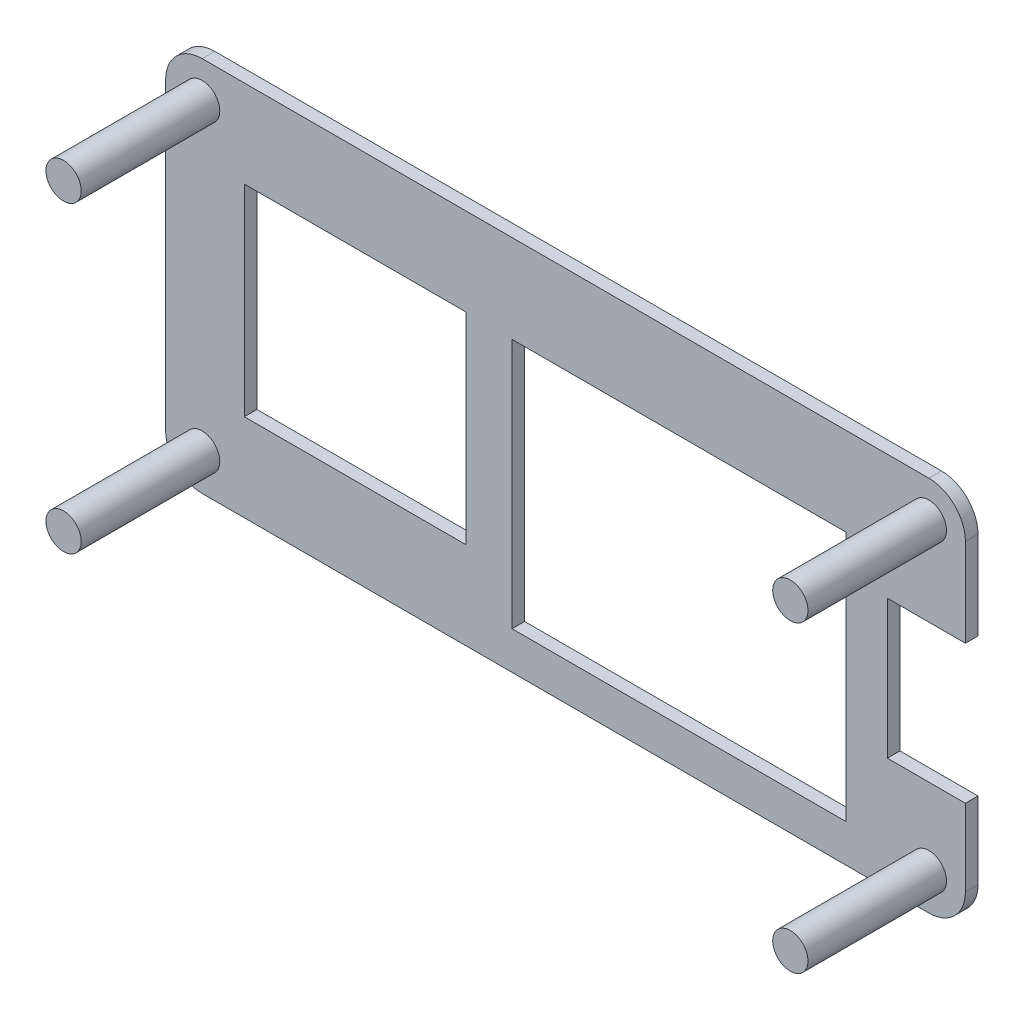
from build123d import *

# Parameters (mm, degrees)
EXTRUDE_1_DEPTH     = 1
SKETCH_2_R          = 1.4
EXTRUDE_2_DEPTH     = 12
SKETCH_10_W         = 17.6
SKETCH_10_H         = 16
SKETCH_10_W_2       = 6.2
SKETCH_10_H_2       = 11
SKETCH_10_W_3       = 26.5
SKETCH_10_H_3       = 19.9
CUT_EXTRUDE_1_DEPTH = 2


with BuildPart() as part:
    # 草图1 → 凸台-拉伸1 (new body)
    with BuildSketch(Plane.XY):
        with BuildLine():
            Line((0, -2.9), (57.7, -2.9))
            ThreePointArc((57.7, -2.9), (59.750609665, -2.050609665), (60.6, 0))
            Line((60.6, 0), (60.6, 24.1))
            ThreePointArc((60.6, 24.1), (59.750609665, 26.150609665), (57.7, 27))
            Line((57.7, 27), (0, 27))
            ThreePointArc((0, 27), (-2.050609665, 26.150609665), (-2.9, 24.1))
            Line((-2.9, 24.1), (-2.9, 0))
            ThreePointArc((-2.9, 0), (-2.050609665, -2.050609665), (0, -2.9))
        make_face()
    extrude(amount=EXTRUDE_1_DEPTH)

    # 草图2 → 凸台-拉伸2 (add)
    with BuildSketch(Plane.XY):
        with Locations((0, 24.1)):
            Circle(SKETCH_2_R)
        Circle(SKETCH_2_R)
        with Locations((57.7, 0)):
            Circle(SKETCH_2_R)
        with Locations((57.7, 24.1)):
            Circle(SKETCH_2_R)
    extrude(amount=EXTRUDE_2_DEPTH)

    # 草图10 → 切除-拉伸1 (cut, through all)
    with BuildSketch(Plane.XY.offset(1)):
        with Locations((12.15, 12.05)):
            Rectangle(SKETCH_10_W, SKETCH_10_H)
        with Locations((57.5, 11.6)):
            Rectangle(SKETCH_10_W_2, SKETCH_10_H_2)
        with Locations((37.85, 10.05)):
            Rectangle(SKETCH_10_W_3, SKETCH_10_H_3)
    extrude(amount=-CUT_EXTRUDE_1_DEPTH, mode=Mode.SUBTRACT)


solid = part.part
